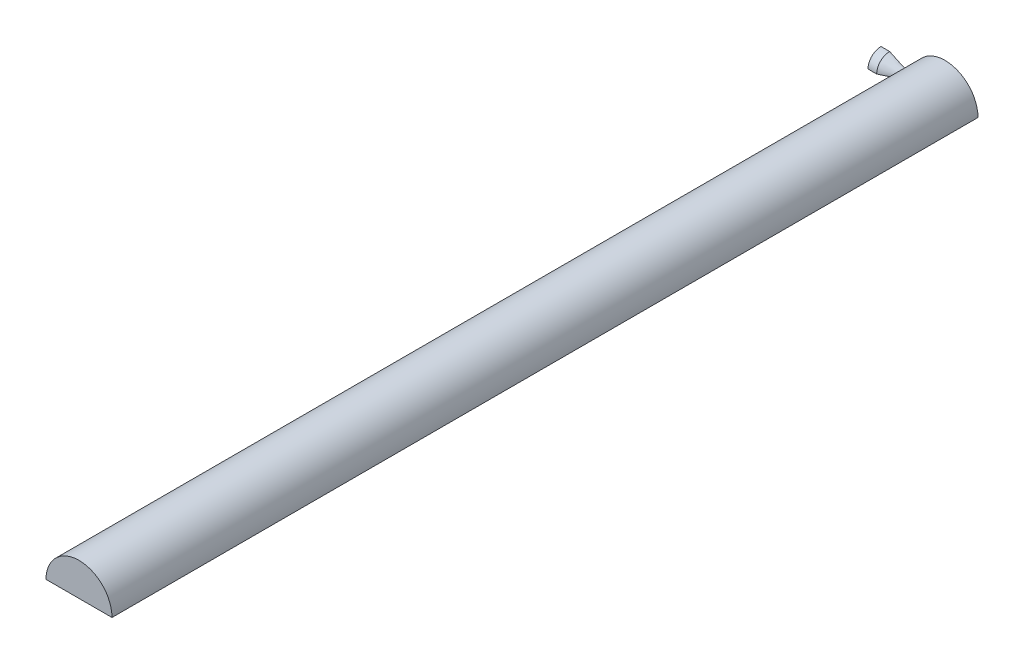
from build123d import *

# Parameters (mm, degrees)
REVOLVE3_ANGLE      = 90
BOSS_EXTRUDE2_DEPTH = 1000


with BuildPart() as part:
    # Sketch2 → Revolve3 (revolve)
    with BuildSketch(Plane.XY):
        with BuildLine():
            Line((-0.654182434, 15.02), (-10.654182434, 15.02))
            Line((-10.654182434, 15.02), (-10.654182434, 0))
            Line((-10.654182434, 0), (0, 0))
            Line((0, 0), (25.4, 0))
            Line((25.4, 0), (35.4, 0))
            Line((35.4, 0), (35.4, 4.5))
            Line((35.4, 4.5), (25.4, 4.5))
            add(Edge.make_bspline(
                [(-0.654182434, 15.02), (-0.219836229, 14.810704372), (0.610598489, 14.410982375), (2.74095302, 13.386545583), (4.34709547, 12.619135975), (6.701613478, 11.49599419), (8.606916476, 10.59589253), (10.790885987, 9.570629713), (12.810835282, 8.63757915), (14.944119423, 7.669787097), (16.950761864, 6.79193378), (18.75556814, 6.044207346), (20.238794329, 5.486207444), (21.39416777, 5.103578745), (22.215591012, 4.870934478), (22.897035956, 4.710298297), (23.464492683, 4.605633048), (23.954091395, 4.538072471), (24.354277235, 4.503624983), (24.669284768, 4.488813447), (24.918595629, 4.485402054), (25.124701431, 4.488218611), (25.279381224, 4.493757229), (25.359889237, 4.497669109), (25.4, 4.5)],
                knots=[0.083771138, 0.083771138, 0.083771138, 0.083771138, 0.083771138, 0.152014176, 0.220257214, 0.288500251, 0.356743288, 0.424986327, 0.493229366, 0.561472406, 0.629715448, 0.697958493, 0.757156968, 0.791278497, 0.81934393, 0.841893906, 0.858954658, 0.874282948, 0.887931591, 0.900718778, 0.906405686, 0.912092593, 0.917779499, 0.923466404, 0.923466404, 0.923466404, 0.923466404, 0.923466404], degree=4))
        make_face()
    revolve(axis=Axis((0, 0, 0), (1, 0, 0)), revolution_arc=REVOLVE3_ANGLE)

    # Sketch11 → Boss-Extrude2 (add)
    with BuildSketch(Plane.XY):
        with BuildLine():
            Line((25.133318649, 0), (101.333318649, 0))
            ThreePointArc((101.333318649, 0), (63.233318649, 38.1), (25.133318649, 0))
        make_face()
    extrude(amount=BOSS_EXTRUDE2_DEPTH)


solid = part.part
